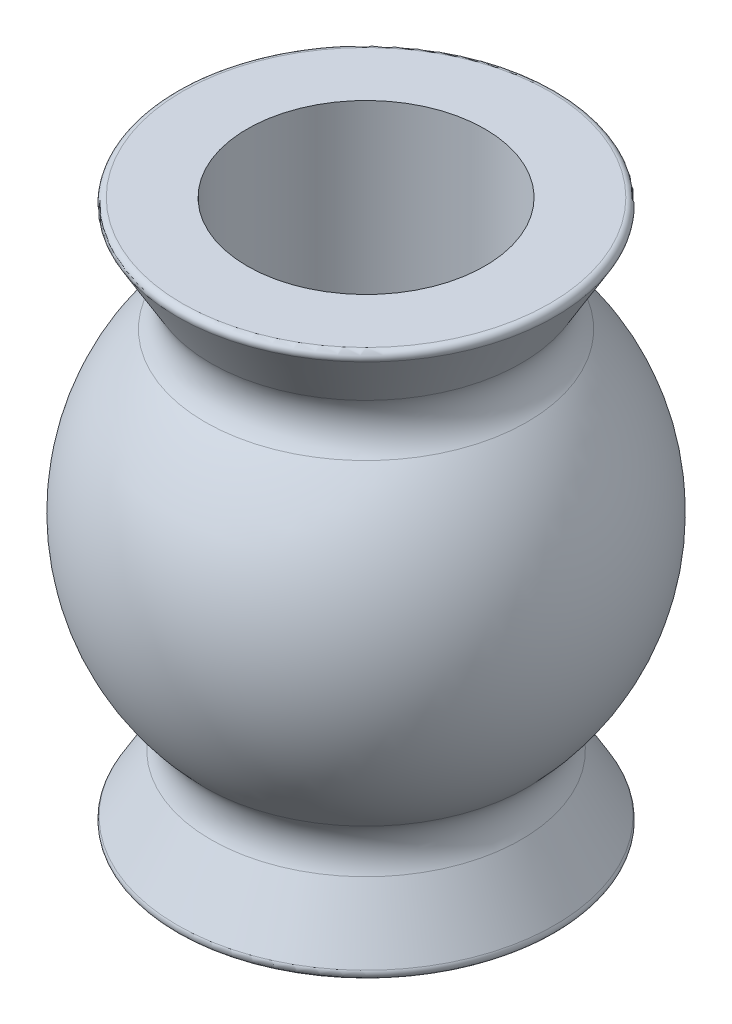
from build123d import *

# Parameters (mm, degrees)
FILLET1_R = 0.508
FILLET2_R = 0.0762


with BuildPart() as part:
    # Sketch1 → Revolve1 (revolve)
    with BuildSketch(Plane.XY):
        with BuildLine():
            Line((1.524, 0), (1.524, 6.985))
            Line((1.524, 6.985), (2.4892, 6.985))
            Line((2.4892, 6.985), (1.777274138, 5.7785))
            ThreePointArc((1.777274138, 5.7785), (2.8956, 3.4925), (1.777274138, 1.2065))
            Line((1.777274138, 1.2065), (2.4892, 0))
            Line((2.4892, 0), (1.524, 0))
        make_face()
    revolve(axis=Axis((0, 0, 0), (0, 1, 0)))

    # Fillet1
    fillet1_edges = [part.edges().sort_by_distance(p)[0] for p in [
        (-1.777274138, 1.2065, 0),
        (-1.777274138, 5.7785, 0),
    ]]
    fillet(fillet1_edges, radius=FILLET1_R)

    # Fillet2
    fillet2_edges = [part.edges().sort_by_distance(p)[0] for p in [
        (-2.4892, 0, 0),
        (-2.4892, 6.985, 0),
    ]]
    fillet(fillet2_edges, radius=FILLET2_R)


solid = part.part
